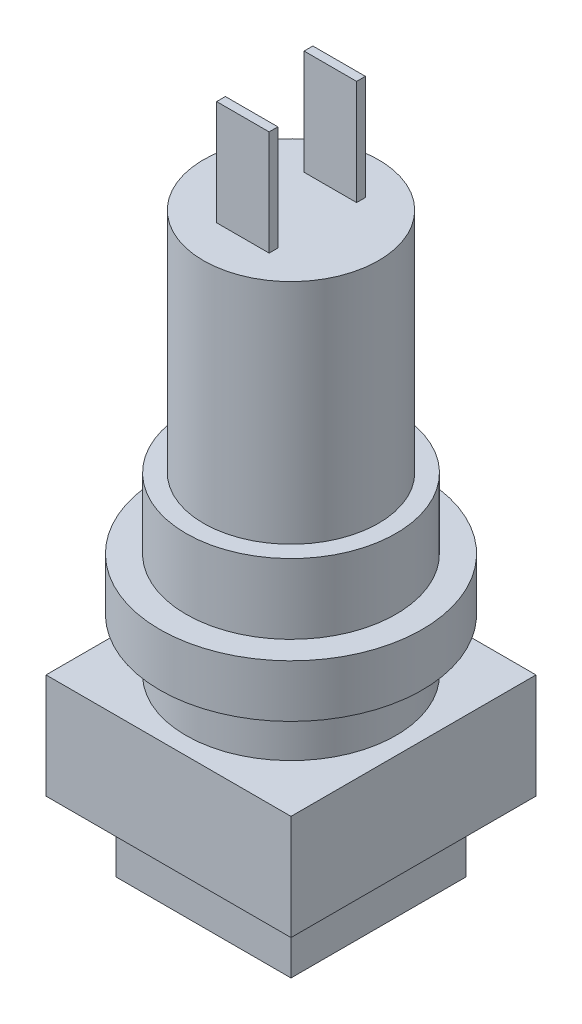
from build123d import *

# Parameters (mm, degrees)
SKETCH1_W           = 10
SKETCH1_H           = 10
BOSS_EXTRUDE1_DEPTH = 4
SKETCH2_W           = 14
SKETCH2_H           = 14
BOSS_EXTRUDE2_DEPTH = 6
SKETCH3_R           = 6
BOSS_EXTRUDE3_DEPTH = 3
SKETCH4_R           = 7.5
BOSS_EXTRUDE4_DEPTH = 3
SKETCH5_R           = 6
BOSS_EXTRUDE5_DEPTH = 4
SKETCH6_R           = 5
BOSS_EXTRUDE6_DEPTH = 13
SKETCH7_W           = 3
SKETCH7_H           = 0.5
BOSS_EXTRUDE7_DEPTH = 6


with BuildPart() as part:
    # Sketch1 → Boss-Extrude1 (new body)
    with BuildSketch(Plane(origin=(0, 0, 0), x_dir=(1, 0, 0), z_dir=(0, 1, 0))):
        Rectangle(SKETCH1_W, SKETCH1_H)
    extrude(amount=BOSS_EXTRUDE1_DEPTH)

    # Sketch2 → Boss-Extrude2 (add)
    with BuildSketch(Plane(origin=(0, 4, 0), x_dir=(1, 0, 0), z_dir=(0, 1, 0))):
        Rectangle(SKETCH2_W, SKETCH2_H)
    extrude(amount=BOSS_EXTRUDE2_DEPTH)

    # Sketch3 → Boss-Extrude3 (add)
    with BuildSketch(Plane(origin=(0, 10, 0), x_dir=(1, 0, 0), z_dir=(0, 1, 0))):
        Circle(SKETCH3_R)
    extrude(amount=BOSS_EXTRUDE3_DEPTH)

    # Sketch4 → Boss-Extrude4 (add)
    with BuildSketch(Plane(origin=(0, 13, 0), x_dir=(1, 0, 0), z_dir=(0, 1, 0))):
        Circle(SKETCH4_R)
    extrude(amount=BOSS_EXTRUDE4_DEPTH)

    # Sketch5 → Boss-Extrude5 (add)
    with BuildSketch(Plane(origin=(0, 16, 0), x_dir=(1, 0, 0), z_dir=(0, 1, 0))):
        Circle(SKETCH5_R)
    extrude(amount=BOSS_EXTRUDE5_DEPTH)

    # Sketch6 → Boss-Extrude6 (add)
    with BuildSketch(Plane(origin=(0, 20, 0), x_dir=(1, 0, 0), z_dir=(0, 1, 0))):
        Circle(SKETCH6_R)
    extrude(amount=BOSS_EXTRUDE6_DEPTH)

    # Sketch7 → Boss-Extrude7 (add)
    with BuildSketch(Plane(origin=(0, 33, 0), x_dir=(1, 0, 0), z_dir=(0, 1, 0))):
        with Locations((0, -2.5)):
            Rectangle(SKETCH7_W, SKETCH7_H)
        with Locations((0, 2.5)):
            Rectangle(SKETCH7_W, SKETCH7_H)
    extrude(amount=BOSS_EXTRUDE7_DEPTH)


solid = part.part
